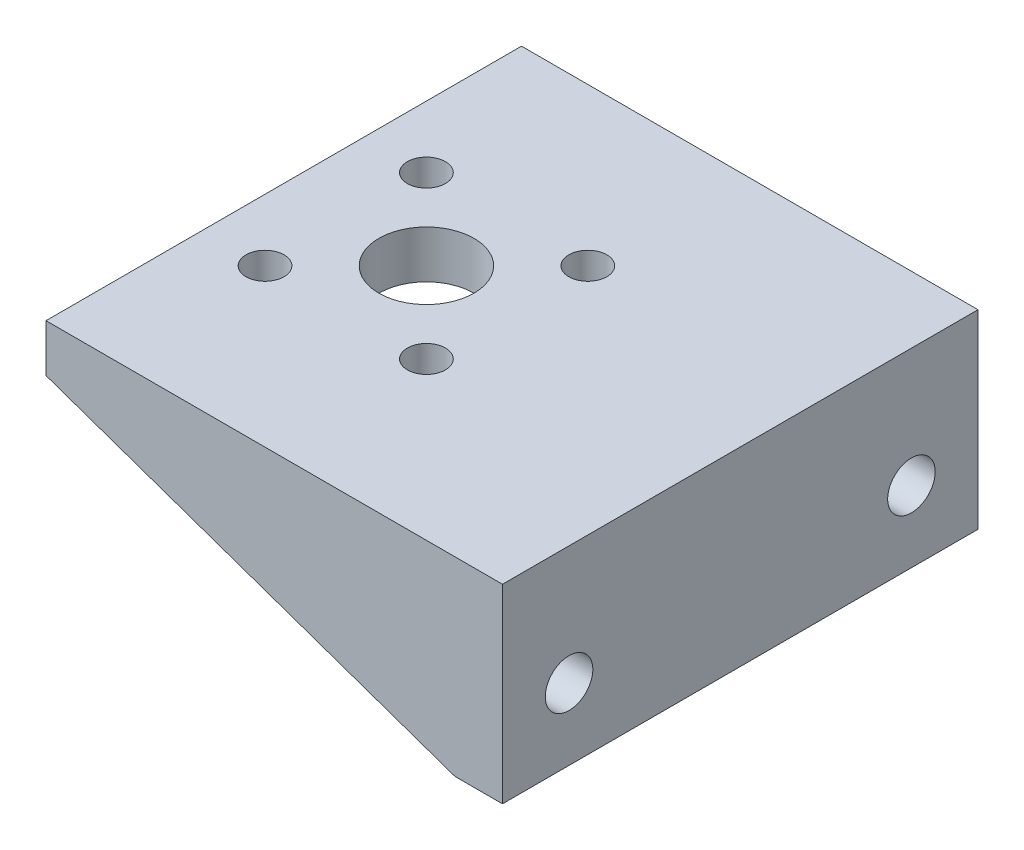
from build123d import *

# Parameters (mm, degrees)
SKETCH1_W           = 30
SKETCH1_H           = 50
BOSS_EXTRUDE1_DEPTH = 5
SKETCH2_R           = 5
CUT_EXTRUDE1_DEPTH  = 5
SKETCH3_R           = 2
CUT_EXTRUDE2_DEPTH  = 10
SKETCH4_W           = 50
SKETCH4_H           = 5
BOSS_EXTRUDE2_DEPTH = 18
SKETCH5_W           = 50
SKETCH5_H           = 20
BOSS_EXTRUDE3_DEPTH = 5
SKETCH6_R           = 2.5
CUT_EXTRUDE3_DEPTH  = 5
BOSS_EXTRUDE4_DEPTH = 3


with BuildPart() as part:
    # Sketch1 → Boss-Extrude1 (new body)
    with BuildSketch(Plane(origin=(0, 0, 0), x_dir=(1, 0, 0), z_dir=(0, 1, 0))):
        Rectangle(SKETCH1_W, SKETCH1_H)
    extrude(amount=BOSS_EXTRUDE1_DEPTH)

    # Sketch2 → Cut-Extrude1 (cut)
    with BuildSketch(Plane(origin=(0, 5, 0), x_dir=(1, 0, 0), z_dir=(0, 1, 0))):
        Circle(SKETCH2_R)
    extrude(amount=-CUT_EXTRUDE1_DEPTH, mode=Mode.SUBTRACT)

    # Sketch3 → Cut-Extrude2 (cut)
    with BuildSketch(Plane(origin=(0, 5, 0), x_dir=(1, 0, 0), z_dir=(0, 1, 0))):
        with Locations((-8.485281374, 8.485281374)):
            Circle(SKETCH3_R)
        with Locations((8.485281374, 8.485281374)):
            Circle(SKETCH3_R)
        with Locations((-8.485281374, -8.485281374)):
            Circle(SKETCH3_R)
        with Locations((8.485281374, -8.485281374)):
            Circle(SKETCH3_R)
    extrude(amount=-CUT_EXTRUDE2_DEPTH, mode=Mode.SUBTRACT)

    # Sketch4 → Boss-Extrude2 (add)
    with BuildSketch(Plane(origin=(15, 0, 0), x_dir=(0, 0, -1), z_dir=(1, 0, 0))):
        with Locations((0, 2.5)):
            Rectangle(SKETCH4_W, SKETCH4_H)
    extrude(amount=BOSS_EXTRUDE2_DEPTH)

    # Sketch5 → Boss-Extrude3 (add)
    with BuildSketch(Plane(origin=(33, 0, 0), x_dir=(0, 0, -1), z_dir=(1, 0, 0))):
        with Locations((0, -5)):
            Rectangle(SKETCH5_W, SKETCH5_H)
    extrude(amount=-BOSS_EXTRUDE3_DEPTH)

    # Sketch6 → Cut-Extrude3 (cut)
    with BuildSketch(Plane(origin=(33, 0, 0), x_dir=(0, 0, -1), z_dir=(1, 0, 0))):
        with Locations((18, -7.5)):
            Circle(SKETCH6_R)
        with Locations((-18, -7.5)):
            Circle(SKETCH6_R)
    extrude(amount=-CUT_EXTRUDE3_DEPTH, mode=Mode.SUBTRACT)

    # Sketch7 → Boss-Extrude4 (add)
    with BuildSketch(Plane.XY.offset(25)):
        Polygon((28, -15), (-15, 0), (28, 0), align=None)
    boss_extrude4 = extrude(amount=-BOSS_EXTRUDE4_DEPTH)

    # Mirror1: Boss-Extrude4 across plane
    add(boss_extrude4.mirror(Plane.XY))


solid = part.part
